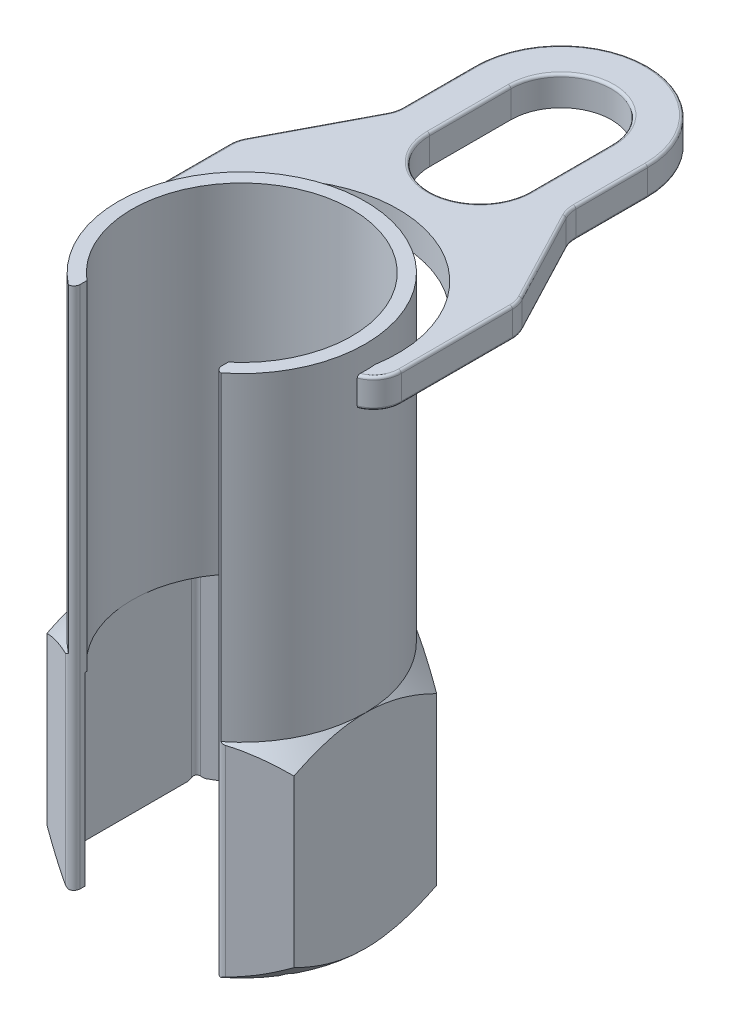
from build123d import *
from build123d.topology import SkipClean

# Parameters (mm, degrees)
EXTRUDE1_DEPTH     = 39
EXTRUDE2_DEPTH     = 61
SKETCH8_OUTSIDE_W  = 275.206
SKETCH8_OUTSIDE_H  = 274.714
SKETCH8_OUTSIDE_R  = 23.599192253
CUT_EXTRUDE4_DEPTH = 101
CUT_EXTRUDE4_DRAFT = -45
SKETCH19_OUTSIDE_W = 153.206
SKETCH19_OUTSIDE_H = 152.714
SKETCH19_OUTSIDE_R = 23.599092253
CUT_EXTRUDE6_DEPTH = 40
CUT_EXTRUDE6_DRAFT = -45
CUT_EXTRUDE9_START = -35.349092
CUT_EXTRUDE9_DEPTH = 35.349098
FILLET1_R          = 1.2
EXTRUDE7_DEPTH     = 5.6
CUT_EXTRUDE8_REACH = 97.6
FILLET4_R          = 0.5


with BuildPart() as part:
    # Sketch1 → Extrude1 (new body)
    with BuildSketch(Plane(origin=(0, 0, 0), x_dir=(1, 0, 0), z_dir=(0, 1, 0))):
        with BuildLine():
            Line((-13.5, -16.085707942), (-13.5, -19.455771366))
            Line((-13.5, -19.455771366), (-23.599192253, -13.625))
            Line((-23.599192253, -13.625), (-23.599192253, 13.625))
            Line((-23.599192253, 13.625), (0, 27.25))
            Line((0, 27.25), (23.599192253, 13.625))
            Line((23.599192253, 13.625), (23.599192253, -13.625))
            Line((23.599192253, -13.625), (13.5, -19.455771366))
            Line((13.5, -19.455771366), (13.5, -16.085707942))
            ThreePointArc((13.5, -16.085707942), (0, 21), (-13.5, -16.085707942))
        make_face()
    extrude(amount=EXTRUDE1_DEPTH)

    # Sketch3 → Extrude2 (add)
    with BuildSketch(Plane(origin=(0, 39, 0), x_dir=(-1, 0, 0), z_dir=(0, 1, 0))):
        with BuildLine():
            Line((-13.5, 19.356320807), (-13.5, 16.085707942))
            ThreePointArc((-13.5, 16.085707942), (0, -21), (13.5, 16.085707942))
            Line((13.5, 16.085707942), (13.5, 19.356320807))
            ThreePointArc((13.5, 19.356320807), (0, -23.599092253), (-13.5, 19.356320807))
        make_face()
    extrude(amount=EXTRUDE2_DEPTH)


with BuildPart() as cut_extrude4_tool:
    # Sketch8 outside → Cut-Extrude4 (with draft: the straight prism first)
    with BuildSketch(Plane.XZ):
        with Locations((0, -3.897)):
            Rectangle(SKETCH8_OUTSIDE_W, SKETCH8_OUTSIDE_H)
        Circle(SKETCH8_OUTSIDE_R, mode=Mode.SUBTRACT)
    extrude(amount=-CUT_EXTRUDE4_DEPTH)
    # Cut-Extrude4: the draft: its side faces are tilted about the plane it starts from
    cut_extrude4_sides = [cut_extrude4_tool.faces().sort_by_distance(p)[0] for p in [
        (0, 50.5, -141.254),
        (137.603, 50.5, -3.897),
        (0, 50.5, 133.46),
        (-137.603, 50.5, -3.897),
        (-23.599192253, 50.5, 0),
    ]]
    draft(cut_extrude4_sides, Plane.XZ, CUT_EXTRUDE4_DRAFT)


with BuildPart() as part_1:
    add(part.part)

    # Cut-Extrude4: cut by cut_extrude4_tool
    add(cut_extrude4_tool.part, mode=Mode.SUBTRACT)


with BuildPart() as cut_extrude6_tool:
    # Sketch19 outside → Cut-Extrude6 (with draft: the straight prism first)
    with BuildSketch(Plane(origin=(0, 39, 0), x_dir=(-1, 0, 0), z_dir=(0, 1, 0))):
        with Locations((0, -3.897)):
            Rectangle(SKETCH19_OUTSIDE_W, SKETCH19_OUTSIDE_H)
        Circle(SKETCH19_OUTSIDE_R, mode=Mode.SUBTRACT)
    extrude(amount=-CUT_EXTRUDE6_DEPTH)
    # Cut-Extrude6: the draft: its side faces are tilted about the plane it starts from
    cut_extrude6_sides = [cut_extrude6_tool.faces().sort_by_distance(p)[0] for p in [
        (0, 19, -80.254),
        (-76.603, 19, -3.897),
        (0, 19, 72.46),
        (76.603, 19, -3.897),
        (23.599092253, 19, 0),
    ]]
    draft(cut_extrude6_sides, Plane(origin=(0, 39, 0), x_dir=(-1, 0, 0), z_dir=(0, 1, 0)), CUT_EXTRUDE6_DRAFT)


with BuildPart() as part_2:
    add(part_1.part)

    # Cut-Extrude6: cut by cut_extrude6_tool
    add(cut_extrude6_tool.part, mode=Mode.SUBTRACT)

    # Sketch26 → Cut-Extrude9 (cut)
    with BuildSketch(Plane.XZ.offset(CUT_EXTRUDE9_START)):
        Polygon((-21, -12.124355653), (0, -24.248711306), (21, -12.124355653), (21, 12.124355653), (0, 24.248711306), (-21, 12.124355653), align=None)
    extrude(amount=CUT_EXTRUDE9_DEPTH, mode=Mode.SUBTRACT)

    # Fillet1
    fillet1_edges = [part_2.edges().sort_by_distance(p)[0] for p in [
        (-21, 17.999305526, -12.124355653),
        (-21, 17.999305526, 12.124355653),
        (21, 17.999305526, 12.124355653),
        (21, 17.999305526, -12.124355653),
        (-13.5, 19.49995, 19.455771366),
        (13.5, 19.49995, 19.455771366),
        (0, 17.999305526, -24.248711306),
    ]]
    fillet(fillet1_edges, radius=FILLET1_R)

    # Sketch16 → Extrude7 (add)
    with BuildSketch(Plane(origin=(0, 90, 0), x_dir=(-1, 0, 0), z_dir=(0, 1, 0))):
        with BuildLine():
            Line((-16.5, -61), (-16.5, -47.306684208))
            ThreePointArc((-16.5, -47.306684208), (-16.654087686, -46.037989424), (-17.107391115, -44.843064543))
            Line((-17.107391115, -44.843064543), (-26.392608885, -27.156935457))
            ThreePointArc((-26.392608885, -27.156935457), (-26.845912314, -25.962010576), (-27, -24.693315792))
            Line((-27, -24.693315792), (-27, -3.466127183))
            ThreePointArc((-27, -3.466127183), (-26.053290434, -0.44307204), (-23.551372681, 1.5))
            ThreePointArc((-23.551372681, 1.5), (0, -23.599092253), (23.551372681, 1.5))
            ThreePointArc((23.551372681, 1.5), (26.053290434, -0.44307204), (27, -3.466127183))
            Line((27, -3.466127183), (27, -24.693315792))
            ThreePointArc((27, -24.693315792), (26.845912314, -25.962010576), (26.392608885, -27.156935457))
            Line((26.392608885, -27.156935457), (17.107391115, -44.843064543))
            ThreePointArc((17.107391115, -44.843064543), (16.654087686, -46.037989424), (16.5, -47.306684208))
            Line((16.5, -47.306684208), (16.5, -61))
            ThreePointArc((16.5, -61), (0, -77.5), (-16.5, -61))
        make_face()
    extrude(amount=EXTRUDE7_DEPTH)

    # Sketch25 → Cut-Extrude8 (cut, up to next)
    with BuildSketch(Plane.XZ.offset(-95.6), mode=Mode.PRIVATE) as cut_extrude8_sk1:
        with BuildLine():
            Line((-9.6, -61), (-9.6, -45.5))
            ThreePointArc((-9.6, -45.5), (0, -35.9), (9.6, -45.5))
            Line((9.6, -45.5), (9.6, -61))
            ThreePointArc((9.6, -61), (0, -70.6), (-9.6, -61))
        make_face()
    cut_extrude8_tool1 = extrude(cut_extrude8_sk1.sketch, amount=CUT_EXTRUDE8_REACH, mode=Mode.PRIVATE) & part_2.part
    add(cut_extrude8_tool1.solids().sort_by_distance((0, 95.6, -53.25))[0], mode=Mode.SUBTRACT)
    # Sketch25 → Cut-Extrude8 (cut, up to next)
    with BuildSketch(Plane.XZ.offset(-95.6), mode=Mode.PRIVATE) as cut_extrude8_sk2:
        with BuildLine():
            ThreePointArc((23.514190506, -2), (0, -23.599092253), (-23.514190506, -2))
            ThreePointArc((-23.514190506, -2), (0, -29.851984303), (23.514190506, -2))
        make_face()
    cut_extrude8_tool2 = extrude(cut_extrude8_sk2.sketch, amount=CUT_EXTRUDE8_REACH, mode=Mode.PRIVATE) & part_2.part
    add(cut_extrude8_tool2.solids().sort_by_distance((0, 95.6, -29.299589))[0], mode=Mode.SUBTRACT)

    # Fillet4
    fillet4_edges = [part_2.edges().sort_by_distance(p)[0] for p in [
        (-26.053290434, 90, -0.44307204),
        (26.053290434, 90, -0.44307204),
        (27, 90, -14.079721488),
        (26.845912314, 90, -25.962010576),
        (21.75, 90, -36),
        (16.654087686, 90, -46.037989424),
        (16.5, 90, -54.153342104),
        (0, 90, -77.5),
        (-16.5, 90, -54.153342104),
        (-16.654087686, 90, -46.037989424),
        (-21.75, 90, -36),
        (-26.845912314, 90, -25.962010576),
        (-27, 90, -14.079721488),
        (-26.053290434, 95.6, -0.44307204),
        (26.053290434, 95.6, -0.44307204),
        (27, 95.6, -14.079721488),
        (26.845912314, 95.6, -25.962010576),
        (21.75, 95.6, -36),
        (16.654087686, 95.6, -46.037989424),
        (16.5, 95.6, -54.153342104),
        (0, 95.6, -77.5),
        (-16.5, 95.6, -54.153342104),
        (-16.654087686, 95.6, -46.037989424),
        (-21.75, 95.6, -36),
        (-26.845912314, 95.6, -25.962010576),
        (-27, 95.6, -14.079721488),
        (0, 95.6, -70.6),
        (9.6, 95.6, -53.25),
        (0, 95.6, -35.9),
        (-9.6, 95.6, -53.25),
    ]]
    fillet(fillet4_edges, radius=FILLET4_R)


solid = part_2.part
